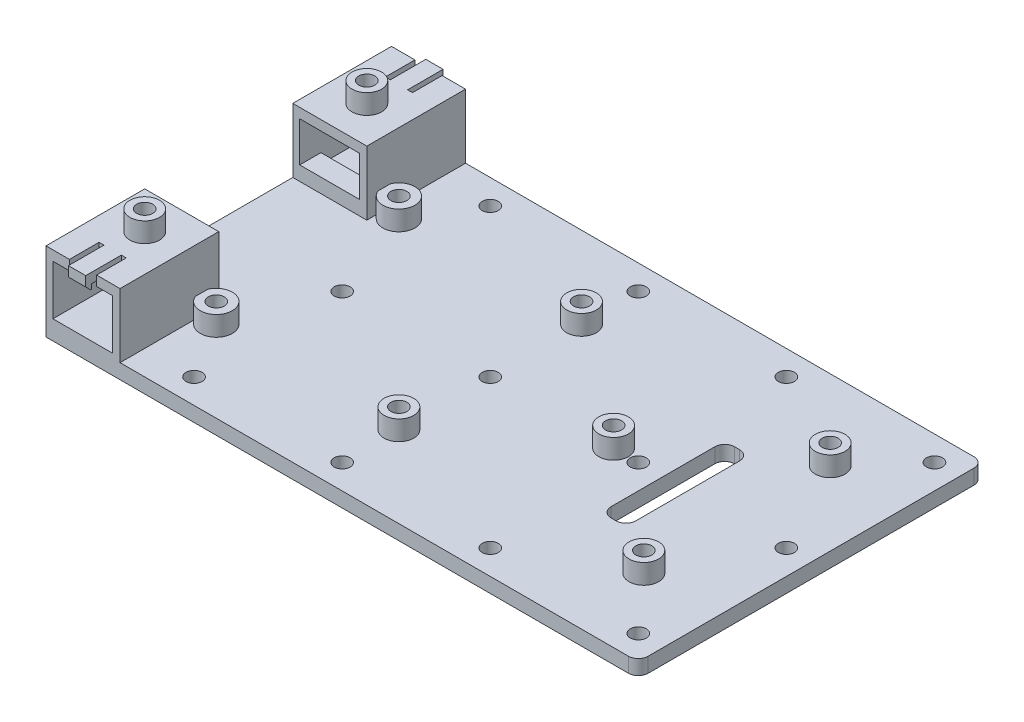
from build123d import *

# Parameters (mm, degrees)
SKETCH1_W                 = 120
SKETCH1_H                 = 70
BOSS_EXTRUDE1_DEPTH       = 3
SKETCH6_W                 = 15
SKETCH6_H                 = 20
BOSS_EXTRUDE3_DEPTH       = 13
SKETCH7_W                 = 12.1
SKETCH7_H                 = 10.1
CUT_EXTRUDE3_DEPTH        = 71
SKETCH8_W                 = 15
SKETCH8_H                 = 4.3
BOSS_EXTRUDE4_DEPTH       = 2
SKETCH9_W                 = 1
SKETCH9_H                 = 6
CUT_EXTRUDE4_DEPTH        = 2
SKETCH10_W                = 3.5
SKETCH10_H                = 3
BOSS_EXTRUDE5_DEPTH       = 1.2
CHAMFER1_SIZE             = 1
CHAMFER1_OF_MIRROR3_SIZE  = 1
CUT_EXTRUDE5_REACH        = 18
SKETCH3_R                 = 1.625
SKETCH12_R                = 3
SKETCH12_R_2              = 1.625
BOSS_EXTRUDE7_DEPTH       = 4
CUT_EXTRUDE6_REACH        = 18
SKETCH11_R                = 1.625
SKETCH13_R                = 3
SKETCH13_R_2              = 1.625
BOSS_EXTRUDE8_DEPTH       = 4
SKETCH14_R                = 1.625
CUT_EXTRUDE7_DEPTH        = 4
SKETCH15_R                = 3.25
SKETCH15_R_2              = 1.625
SKETCH15_R_3              = 3
BOSS_EXTRUDE13_DEPTH      = 4
SKETCH17_W                = 5
SKETCH17_H                = 25
CUT_EXTRUDE8_DEPTH        = 4
SKETCH18_R                = 3
SKETCH18_R_2              = 1.625
BOSS_EXTRUDE14_DEPTH      = 4
FILLET2_R                 = 2
SKETCH19_R                = 1.625
CUT_EXTRUDE9_DEPTH        = 4
LPATTERN1_COUNT           = 2
LPATTERN1_PITCH           = 30
LPATTERN1_COL_COUNT       = 2
LPATTERN1_COL_PITCH       = 30
LPATTERN2_COUNT           = 4
LPATTERN2_PITCH           = 30
LPATTERN2_COPY_1_SKETCH_R = 1.625
LPATTERN2_COPY_1_DEPTH    = 4
LPATTERN2_COPY_2_SKETCH_R = 1.625
LPATTERN2_COPY_2_DEPTH    = 4
LPATTERN2_COPY_3_SKETCH_R = 1.625
LPATTERN2_COPY_3_DEPTH    = 4
LPATTERN2_COPY_4_SKETCH_R = 1.625
LPATTERN2_COPY_4_DEPTH    = 4
LPATTERN2_COPY_5_SKETCH_R = 1.625
LPATTERN2_COPY_5_DEPTH    = 4
LPATTERN2_COPY_6_SKETCH_R = 1.625
LPATTERN2_COPY_6_DEPTH    = 4


with BuildPart() as part:
    # Sketch1 → Boss-Extrude1 (new body)
    with BuildSketch(Plane(origin=(0, 0, 0), x_dir=(1, 0, 0), z_dir=(0, 1, 0))):
        Rectangle(SKETCH1_W, SKETCH1_H)
    extrude(amount=BOSS_EXTRUDE1_DEPTH)

    # Sketch6 → Boss-Extrude3 (add)
    with BuildSketch(Plane(origin=(0, 3, 0), x_dir=(1, 0, 0), z_dir=(0, 1, 0))):
        with Locations((-52.5, 25)):
            Rectangle(SKETCH6_W, SKETCH6_H)
        with Locations((-52.5, -25)):
            Rectangle(SKETCH6_W, SKETCH6_H)
    extrude(amount=BOSS_EXTRUDE3_DEPTH)

    # Sketch7 → Cut-Extrude3 (cut, through all)
    with BuildSketch(Plane(origin=(0, 0, -35), x_dir=(-1, 0, 0), z_dir=(0, 0, -1))):
        with Locations((52.55, 8.95)):
            Rectangle(SKETCH7_W, SKETCH7_H)
    extrude(amount=-CUT_EXTRUDE3_DEPTH, mode=Mode.SUBTRACT)

    # Sketch8 → Boss-Extrude4 (add)
    with BuildSketch(Plane(origin=(0, 3.9, 0), x_dir=(1, 0, 0), z_dir=(0, 1, 0))):
        with Locations((-52.5, -17.15)):
            Rectangle(SKETCH8_W, SKETCH8_H)
    boss_extrude4 = extrude(amount=BOSS_EXTRUDE4_DEPTH)

    # Mirror1: Boss-Extrude4 across plane
    add(boss_extrude4.mirror(Plane.XY))

    # Sketch9 → Cut-Extrude4 (cut)
    with BuildSketch(Plane(origin=(0, 16, 0), x_dir=(1, 0, 0), z_dir=(0, 1, 0))):
        with Locations((-54.75, 32)):
            Rectangle(SKETCH9_W, SKETCH9_H)
        with Locations((-50.25, 32)):
            Rectangle(SKETCH9_W, SKETCH9_H)
    cut_extrude4 = extrude(amount=-CUT_EXTRUDE4_DEPTH, mode=Mode.SUBTRACT)

    # Mirror2: Cut-Extrude4 across plane
    add(cut_extrude4.mirror(Plane.XY), mode=Mode.SUBTRACT)

    # Sketch10 → Boss-Extrude5 (add)
    with BuildSketch(Plane(origin=(0, 0, -35), x_dir=(-1, 0, 0), z_dir=(0, 0, -1))):
        with Locations((52.5, 14.5)):
            Rectangle(SKETCH10_W, SKETCH10_H)
    boss_extrude5 = extrude(amount=BOSS_EXTRUDE5_DEPTH)

    # Chamfer1
    chamfer1_edges = [part.edges().sort_by_distance(p)[0] for p in [
        (-52.5, 13, -36.2),
    ]]
    chamfer(chamfer1_edges, length=CHAMFER1_SIZE)

    # Mirror3: Boss-Extrude5 across plane
    add(boss_extrude5.mirror(Plane.XY))

    # Chamfer1 of Mirror3
    chamfer1_of_mirror3_edges = [part.edges().sort_by_distance(p)[0] for p in [
        (-52.5, 13, 36.2),
    ]]
    chamfer(chamfer1_of_mirror3_edges, length=CHAMFER1_OF_MIRROR3_SIZE)

    # Sketch3 → Cut-Extrude5 (cut, up to next)
    with BuildSketch(Plane.XZ, mode=Mode.PRIVATE) as cut_extrude5_sk1:
        with Locations((45, 18.875)):
            Circle(SKETCH3_R)
    cut_extrude5_tool1 = extrude(cut_extrude5_sk1.sketch, amount=-CUT_EXTRUDE5_REACH, mode=Mode.PRIVATE) & part.part
    add(cut_extrude5_tool1.solids().sort_by_distance((45, 0, 18.875))[0], mode=Mode.SUBTRACT)
    # Sketch3 → Cut-Extrude5 (cut, up to next)
    with BuildSketch(Plane.XZ, mode=Mode.PRIVATE) as cut_extrude5_sk2:
        with Locations((45, -18.875)):
            Circle(SKETCH3_R)
    cut_extrude5_tool2 = extrude(cut_extrude5_sk2.sketch, amount=-CUT_EXTRUDE5_REACH, mode=Mode.PRIVATE) & part.part
    add(cut_extrude5_tool2.solids().sort_by_distance((45, 0, -18.875))[0], mode=Mode.SUBTRACT)

    # Sketch12 → Boss-Extrude7 (add)
    with BuildSketch(Plane(origin=(0, 3, 0), x_dir=(1, 0, 0), z_dir=(0, 1, 0))):
        with Locations((45, 18.875)):
            Circle(SKETCH12_R)
        with Locations((45, 18.875)):
            Circle(SKETCH12_R_2, mode=Mode.SUBTRACT)
    boss_extrude7 = extrude(amount=BOSS_EXTRUDE7_DEPTH)

    # Mirror4: Boss-Extrude7 across plane
    add(boss_extrude7.mirror(Plane.XY))

    # Sketch11 → Cut-Extrude6 (cut, up to next)
    with BuildSketch(Plane.XZ, mode=Mode.PRIVATE) as cut_extrude6_sk1:
        with Locations((20, 0)):
            Circle(SKETCH11_R)
    cut_extrude6_tool1 = extrude(cut_extrude6_sk1.sketch, amount=-CUT_EXTRUDE6_REACH, mode=Mode.PRIVATE) & part.part
    add(cut_extrude6_tool1.solids().sort_by_distance((20, 0, 0))[0], mode=Mode.SUBTRACT)

    # Sketch13 → Boss-Extrude8 (add)
    with BuildSketch(Plane(origin=(0, 3, 0), x_dir=(1, 0, 0), z_dir=(0, 1, 0))):
        with Locations((20, 0)):
            Circle(SKETCH13_R)
        with Locations((20, 0)):
            Circle(SKETCH13_R_2, mode=Mode.SUBTRACT)
    extrude(amount=BOSS_EXTRUDE8_DEPTH)

    # Sketch14 → Cut-Extrude7 (cut, through all)
    with BuildSketch(Plane(origin=(0, 3, 0), x_dir=(1, 0, 0), z_dir=(0, 1, 0))):
        with Locations((-42, 18.5)):
            Circle(SKETCH14_R)
        with Locations((-42, -18.5)):
            Circle(SKETCH14_R)
        with Locations((-5, 18.5)):
            Circle(SKETCH14_R)
        with Locations((-5, -18.5)):
            Circle(SKETCH14_R)
    extrude(amount=-CUT_EXTRUDE7_DEPTH, mode=Mode.SUBTRACT)

    # Sketch15 → Boss-Extrude13 (add)
    with BuildSketch(Plane(origin=(0, 3, 0), x_dir=(1, 0, 0), z_dir=(0, 1, 0))):
        with Locations((-42, 18.5)):
            Circle(SKETCH15_R)
        with Locations((-42, 18.5)):
            Circle(SKETCH15_R_2, mode=Mode.SUBTRACT)
        with Locations((-5, 18.5)):
            Circle(SKETCH15_R_3)
        with Locations((-5, 18.5)):
            Circle(SKETCH15_R_2, mode=Mode.SUBTRACT)
        with Locations((-5, -18.5)):
            Circle(SKETCH15_R_3)
        with Locations((-5, -18.5)):
            Circle(SKETCH15_R_2, mode=Mode.SUBTRACT)
        with Locations((-42, -18.5)):
            Circle(SKETCH15_R)
        with Locations((-42, -18.5)):
            Circle(SKETCH15_R_2, mode=Mode.SUBTRACT)
    extrude(amount=BOSS_EXTRUDE13_DEPTH)

    # Sketch17 → Cut-Extrude8 (cut, through all)
    with BuildSketch(Plane(origin=(0, 3, 0), x_dir=(1, 0, 0), z_dir=(0, 1, 0))):
        with Locations((32.5, 0)):
            Rectangle(SKETCH17_W, SKETCH17_H)
    extrude(amount=-CUT_EXTRUDE8_DEPTH, mode=Mode.SUBTRACT)

    # Sketch18 → Boss-Extrude14 (add)
    with BuildSketch(Plane(origin=(0, 16, 0), x_dir=(1, 0, 0), z_dir=(0, 1, 0))):
        with Locations((-52.5, 22.5)):
            Circle(SKETCH18_R)
        with Locations((-52.5, 22.5)):
            Circle(SKETCH18_R_2, mode=Mode.SUBTRACT)
    boss_extrude14 = extrude(amount=BOSS_EXTRUDE14_DEPTH)

    # Mirror5: Boss-Extrude14 across plane
    add(boss_extrude14.mirror(Plane.XY))

    # Fillet2
    fillet2_edges = [part.edges().sort_by_distance(p)[0] for p in [
        (30, 1.5, 12.5),
        (30, 1.5, -12.5),
        (35, 1.5, -12.5),
        (35, 1.5, 12.5),
        (60, 1.5, -35),
        (60, 1.5, 35),
    ]]
    fillet(fillet2_edges, radius=FILLET2_R)

    # Sketch19 → Cut-Extrude9 (cut, through all)
    with BuildSketch(Plane(origin=(0, 3, 0), x_dir=(1, 0, 0), z_dir=(0, 1, 0))):
        with Locations((55, 0)):
            Circle(SKETCH19_R)
    cut_extrude9 = extrude(amount=-CUT_EXTRUDE9_DEPTH, mode=Mode.SUBTRACT)

    # LPattern1: Cut-Extrude9 ×2
    with Locations(*[(0, 0, i * LPATTERN1_PITCH) for i in range(1, LPATTERN1_COUNT)]):
        add(cut_extrude9, mode=Mode.SUBTRACT)

    # LPattern1 col: Cut-Extrude9 ×2
    with Locations(*[(0, 0, -i * LPATTERN1_COL_PITCH) for i in range(1, LPATTERN1_COL_COUNT)]):
        add(cut_extrude9, mode=Mode.SUBTRACT)

    # LPattern2: Cut-Extrude9 ×4
    with Locations(*[(-i * LPATTERN2_PITCH, 0, 0) for i in range(1, LPATTERN2_COUNT)]):
        add(cut_extrude9, mode=Mode.SUBTRACT)

    # LPattern2 copy 1 sketch → LPattern2 copy 1 (cut, through all)
    with BuildSketch(Plane(origin=(-30, 3, 30), x_dir=(1, 0, 0), z_dir=(0, 1, 0))):
        with Locations((55, 0)):
            Circle(LPATTERN2_COPY_1_SKETCH_R)
    extrude(amount=-LPATTERN2_COPY_1_DEPTH, mode=Mode.SUBTRACT)

    # LPattern2 copy 2 sketch → LPattern2 copy 2 (cut, through all)
    with BuildSketch(Plane(origin=(-60, 3, 30), x_dir=(1, 0, 0), z_dir=(0, 1, 0))):
        with Locations((55, 0)):
            Circle(LPATTERN2_COPY_2_SKETCH_R)
    extrude(amount=-LPATTERN2_COPY_2_DEPTH, mode=Mode.SUBTRACT)

    # LPattern2 copy 3 sketch → LPattern2 copy 3 (cut, through all)
    with BuildSketch(Plane(origin=(-90, 3, 30), x_dir=(1, 0, 0), z_dir=(0, 1, 0))):
        with Locations((55, 0)):
            Circle(LPATTERN2_COPY_3_SKETCH_R)
    extrude(amount=-LPATTERN2_COPY_3_DEPTH, mode=Mode.SUBTRACT)

    # LPattern2 copy 4 sketch → LPattern2 copy 4 (cut, through all)
    with BuildSketch(Plane(origin=(-30, 3, -30), x_dir=(1, 0, 0), z_dir=(0, 1, 0))):
        with Locations((55, 0)):
            Circle(LPATTERN2_COPY_4_SKETCH_R)
    extrude(amount=-LPATTERN2_COPY_4_DEPTH, mode=Mode.SUBTRACT)

    # LPattern2 copy 5 sketch → LPattern2 copy 5 (cut, through all)
    with BuildSketch(Plane(origin=(-60, 3, -30), x_dir=(1, 0, 0), z_dir=(0, 1, 0))):
        with Locations((55, 0)):
            Circle(LPATTERN2_COPY_5_SKETCH_R)
    extrude(amount=-LPATTERN2_COPY_5_DEPTH, mode=Mode.SUBTRACT)

    # LPattern2 copy 6 sketch → LPattern2 copy 6 (cut, through all)
    with BuildSketch(Plane(origin=(-90, 3, -30), x_dir=(1, 0, 0), z_dir=(0, 1, 0))):
        with Locations((55, 0)):
            Circle(LPATTERN2_COPY_6_SKETCH_R)
    extrude(amount=-LPATTERN2_COPY_6_DEPTH, mode=Mode.SUBTRACT)


solid = part.part
